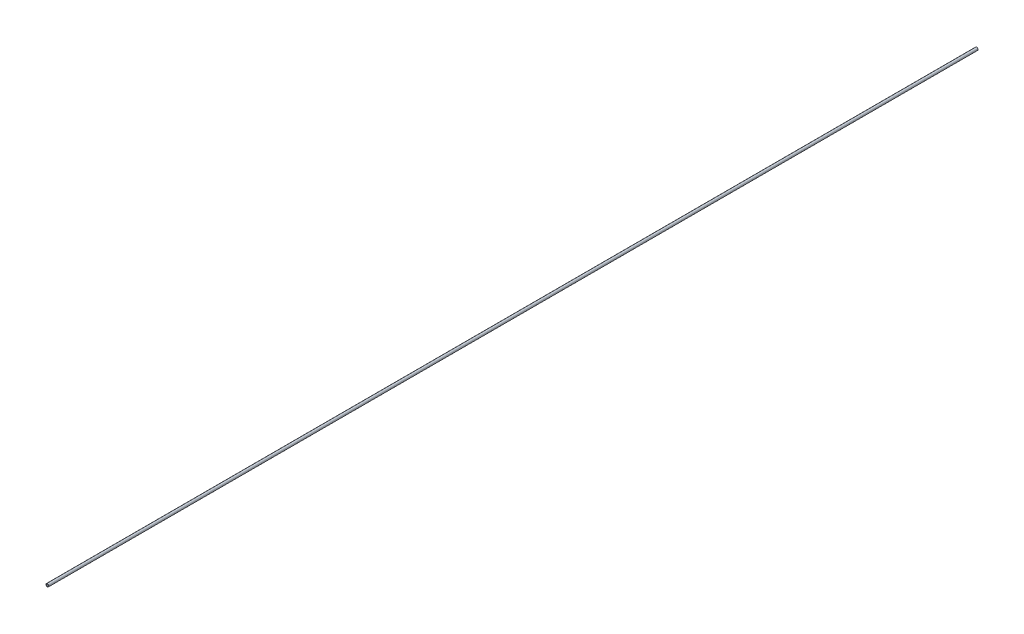
from build123d import *

# Parameters (mm, degrees)
SKETCH1_R           = 3
SKETCH1_R_2         = 2
BOSS_EXTRUDE1_DEPTH = 2000


with BuildPart() as part:
    # Sketch1 → Boss-Extrude1 (new body)
    with BuildSketch(Plane.XY):
        Circle(SKETCH1_R)
        Circle(SKETCH1_R_2, mode=Mode.SUBTRACT)
    extrude(amount=BOSS_EXTRUDE1_DEPTH)


solid = part.part
